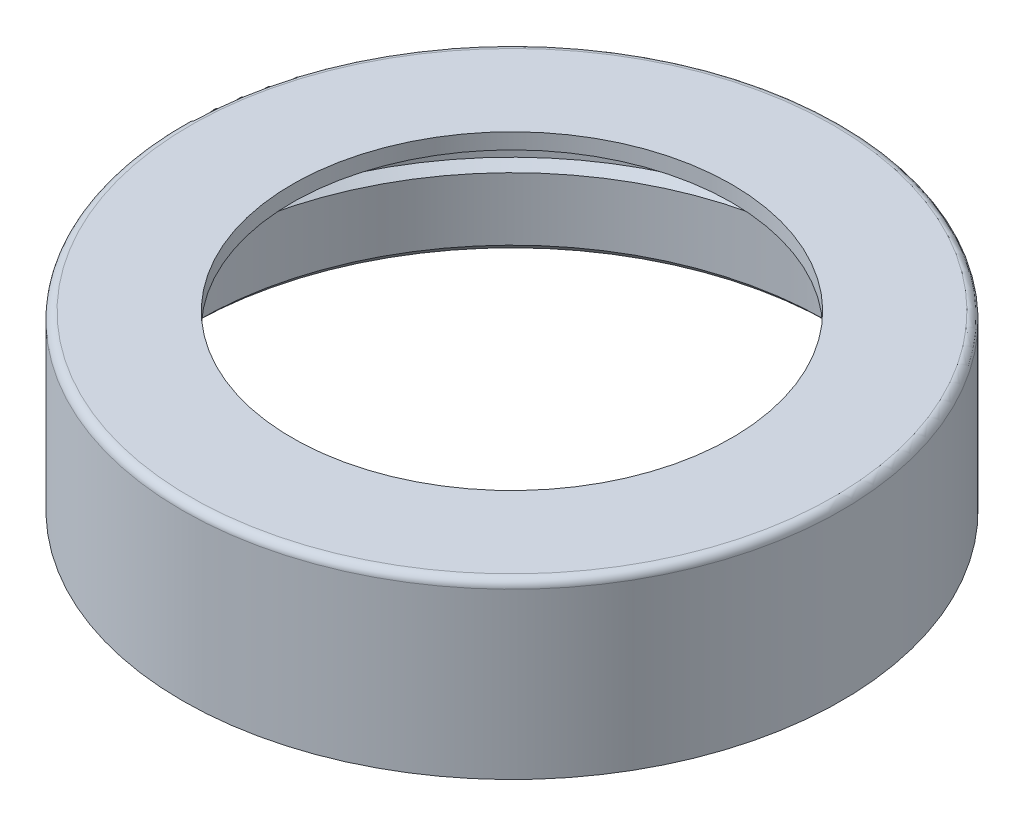
from build123d import *

# Parameters (mm, degrees)
FILETE1_R = 0.5


with BuildPart() as part:
    # Esboço1 → Revolução2 (revolve)
    with BuildSketch(Plane.XY):
        Polygon((-21, 0), (-21, 11), (-14, 11), (-14, 10), (-20, 10), (-20, 6), (-20.5, 6), (-20.5, 5), (-20, 4.5), (-20, 0.5), (-20.5, 0), align=None)
    revolve(axis=Axis((0, 0, 0), (0, 1, 0)))

    # Filete1
    filete1_edges = [part.edges().sort_by_distance(p)[0] for p in [
        (21, 11, 0),
    ]]
    fillet(filete1_edges, radius=FILETE1_R)


solid = part.part
